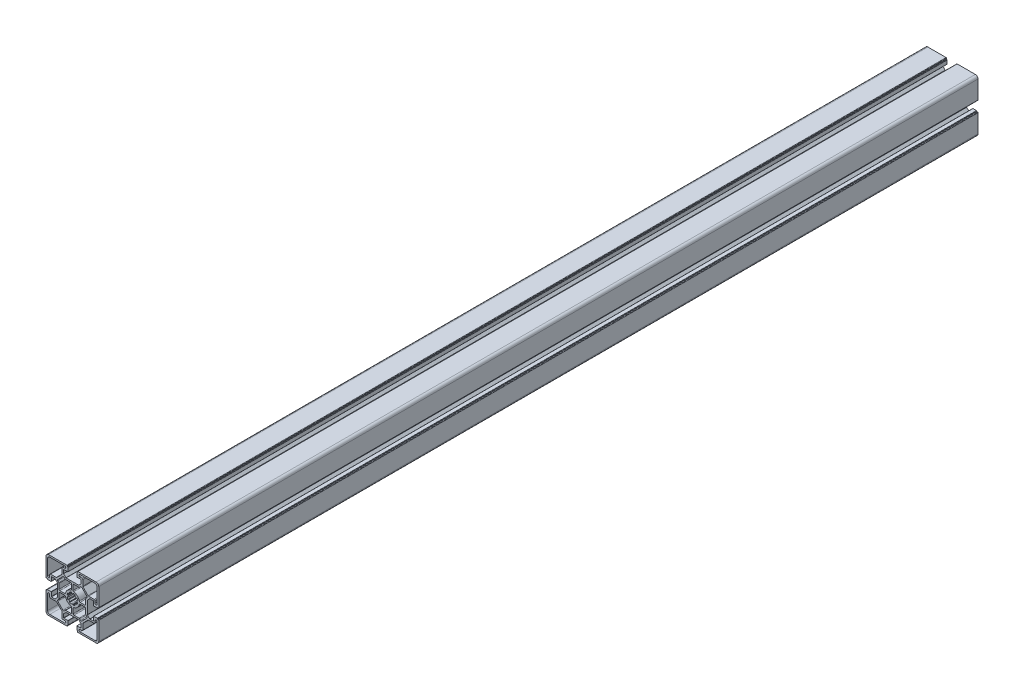
from build123d import *

# Parameters (mm, degrees)
EXTRUDE_1_DEPTH = 1000


with BuildPart() as part:
    # Эскиз1 → Бобышка-Вытянуть1 (new body)
    with BuildSketch(Plane.XY):
        with BuildLine():
            Line((10.939107633, 13.594528117), (8.256260181, 10.911682664))
            ThreePointArc((8.256260181, 10.911682664), (8.1913755, 10.868328133), (8.114838815, 10.853104047))
            Line((8.114838815, 10.853104047), (-6.219481344, 10.853104047))
            ThreePointArc((-6.219481344, 10.853104047), (-6.29601803, 10.868328133), (-6.36090271, 10.911682664))
            Line((-6.36090271, 10.911682664), (-9.043750162, 13.594528117))
            ThreePointArc((-9.043750162, 13.594528117), (-9.087104924, 13.659413063), (-9.102329092, 13.735950089))
            Line((-9.102329092, 13.735950089), (-9.102329092, 17.653103196))
            ThreePointArc((-9.102329092, 17.653103196), (-9.043750199, 17.794525153), (-8.902328242, 17.853104046))
            Line((-8.902328242, 17.853104046), (-4.252328945, 17.853104046))
            ThreePointArc((-4.252328945, 17.853104046), (-4.110906987, 17.911682939), (-4.052328095, 18.053104897))
            Line((-4.052328095, 18.053104897), (-4.052328095, 22.05310527))
            ThreePointArc((-4.052328095, 22.05310527), (-4.140195702, 22.265236439), (-4.35232687, 22.353104046))
            Line((-4.35232687, 22.353104046), (-4.552319317, 22.353104046))
            ThreePointArc((-4.552319317, 22.353104046), (-4.764450486, 22.440971653), (-4.852318093, 22.653102822))
            Line((-4.852318093, 22.653102822), (-4.852318093, 23.353104321))
            ThreePointArc((-4.852318093, 23.353104321), (-4.998764593, 23.706657447), (-5.352317719, 23.853103947))
            Line((-5.352317719, 23.853103947), (-26.052328498, 23.853103947))
            ThreePointArc((-26.052328498, 23.853103947), (-28.173647609, 22.974424801), (-29.052326755, 20.85310569))
            Line((-29.052326755, 20.85310569), (-29.052326755, 0.153095213))
            ThreePointArc((-29.052326755, 0.153095213), (-28.905880255, -0.200457913), (-28.552327128, -0.346904413))
            Line((-28.552327128, -0.346904413), (-27.852326458, -0.346904413))
            ThreePointArc((-27.852326458, -0.346904413), (-27.640194582, -0.434772313), (-27.552326682, -0.646904189))
            Line((-27.552326682, -0.646904189), (-27.552326682, -0.846892625))
            ThreePointArc((-27.552326682, -0.846892625), (-27.464458779, -1.05902451), (-27.252326894, -1.146892413))
            Line((-27.252326894, -1.146892413), (-23.252327233, -1.146892413))
            ThreePointArc((-23.252327233, -1.146892413), (-23.110905629, -1.088313667), (-23.052326882, -0.946892063))
            Line((-23.052326882, -0.946892063), (-23.052326882, 3.703106436))
            ThreePointArc((-23.052326882, 3.703106436), (-22.993748136, 3.84452804), (-22.852326532, 3.903106787))
            Line((-22.852326532, 3.903106787), (-18.935168424, 3.903106787))
            ThreePointArc((-18.935168424, 3.903106787), (-18.858631895, 3.887882725), (-18.793747359, 3.844528263))
            Line((-18.793747359, 3.844528263), (-16.110902259, 1.161683164))
            ThreePointArc((-16.110902259, 1.161683164), (-16.067547166, 1.096797682), (-16.052322882, 1.020260037))
            Line((-16.052322882, 1.020260037), (-16.052322882, -13.313984723))
            ThreePointArc((-16.052322882, -13.313984723), (-16.067547166, -13.390522368), (-16.110902259, -13.45540785))
            Line((-16.110902259, -13.45540785), (-18.793747359, -16.138252949))
            ThreePointArc((-18.793747359, -16.138252949), (-18.858631895, -16.181607411), (-18.935168424, -16.196831473))
            Line((-18.935168424, -16.196831473), (-22.852326532, -16.196831473))
            ThreePointArc((-22.852326532, -16.196831473), (-22.993748136, -16.138252726), (-23.052326882, -15.996831122))
            Line((-23.052326882, -15.996831122), (-23.052326882, -11.346832623))
            ThreePointArc((-23.052326882, -11.346832623), (-23.110905629, -11.205411019), (-23.252327233, -11.146832273))
            Line((-23.252327233, -11.146832273), (-27.252326894, -11.146832273))
            ThreePointArc((-27.252326894, -11.146832273), (-27.464458779, -11.234700176), (-27.552326682, -11.446832061))
            Line((-27.552326682, -11.446832061), (-27.552326682, -11.646820497))
            ThreePointArc((-27.552326682, -11.646820497), (-27.640194582, -11.858952373), (-27.852326458, -11.946820273))
            Line((-27.852326458, -11.946820273), (-28.552327128, -11.946820273))
            ThreePointArc((-28.552327128, -11.946820273), (-28.905880255, -12.093266773), (-29.052326755, -12.446819899))
            Line((-29.052326755, -12.446819899), (-29.052326755, -33.146830376))
            ThreePointArc((-29.052326755, -33.146830376), (-28.173647609, -35.268149487), (-26.052328498, -36.146828633))
            Line((-26.052328498, -36.146828633), (-5.352317719, -36.146828633))
            ThreePointArc((-5.352317719, -36.146828633), (-4.998764593, -36.000382133), (-4.852318093, -35.646829007))
            Line((-4.852318093, -35.646829007), (-4.852318093, -34.946827508))
            ThreePointArc((-4.852318093, -34.946827508), (-4.764450486, -34.734696339), (-4.552319317, -34.646828732))
            Line((-4.552319317, -34.646828732), (-4.35232687, -34.646828732))
            ThreePointArc((-4.35232687, -34.646828732), (-4.140195702, -34.558961125), (-4.052328095, -34.346829956))
            Line((-4.052328095, -34.346829956), (-4.052328095, -30.346829583))
            ThreePointArc((-4.052328095, -30.346829583), (-4.110906987, -30.205407625), (-4.252328945, -30.146828732))
            Line((-4.252328945, -30.146828732), (-8.902328242, -30.146828732))
            ThreePointArc((-8.902328242, -30.146828732), (-9.043750199, -30.088249839), (-9.102329092, -29.946827882))
            Line((-9.102329092, -29.946827882), (-9.102329092, -26.029674775))
            ThreePointArc((-9.102329092, -26.029674775), (-9.087104924, -25.953137749), (-9.043750162, -25.888252803))
            Line((-9.043750162, -25.888252803), (-6.36090271, -23.20540735))
            ThreePointArc((-6.36090271, -23.20540735), (-6.29601803, -23.162052819), (-6.219481344, -23.146828733))
            Line((-6.219481344, -23.146828733), (8.114838815, -23.146828733))
            ThreePointArc((8.114838815, -23.146828733), (8.1913755, -23.162052819), (8.256260181, -23.20540735))
            Line((8.256260181, -23.20540735), (10.939107633, -25.888252803))
            ThreePointArc((10.939107633, -25.888252803), (10.982462395, -25.953137749), (10.997686563, -26.029674775))
            Line((10.997686563, -26.029674775), (10.997686563, -29.946827882))
            ThreePointArc((10.997686563, -29.946827882), (10.93910767, -30.088249839), (10.797685712, -30.146828732))
            Line((10.797685712, -30.146828732), (6.147686416, -30.146828732))
            ThreePointArc((6.147686416, -30.146828732), (6.006264458, -30.205407625), (5.947685565, -30.346829583))
            Line((5.947685565, -30.346829583), (5.947685565, -34.346829956))
            ThreePointArc((5.947685565, -34.346829956), (6.035553173, -34.558961125), (6.247684341, -34.646828732))
            Line((6.247684341, -34.646828732), (6.447676788, -34.646828732))
            ThreePointArc((6.447676788, -34.646828732), (6.659807956, -34.734696339), (6.747675564, -34.946827508))
            Line((6.747675564, -34.946827508), (6.747675564, -35.646829007))
            ThreePointArc((6.747675564, -35.646829007), (6.894122064, -36.000382133), (7.24767519, -36.146828633))
            Line((7.24767519, -36.146828633), (27.947685969, -36.146828633))
            ThreePointArc((27.947685969, -36.146828633), (30.06900508, -35.268149487), (30.947684225, -33.146830376))
            Line((30.947684225, -33.146830376), (30.947684225, -12.446819899))
            ThreePointArc((30.947684225, -12.446819899), (30.801237725, -12.093266773), (30.447684599, -11.946820273))
            Line((30.447684599, -11.946820273), (29.747683929, -11.946820273))
            ThreePointArc((29.747683929, -11.946820273), (29.535552053, -11.858952373), (29.447684153, -11.646820497))
            Line((29.447684153, -11.646820497), (29.447684153, -11.446832061))
            ThreePointArc((29.447684153, -11.446832061), (29.359816249, -11.234700176), (29.147684365, -11.146832273))
            Line((29.147684365, -11.146832273), (25.147684704, -11.146832273))
            ThreePointArc((25.147684704, -11.146832273), (25.006263099, -11.205411019), (24.947684353, -11.346832623))
            Line((24.947684353, -11.346832623), (24.947684353, -15.996831122))
            ThreePointArc((24.947684353, -15.996831122), (24.889105607, -16.138252726), (24.747684002, -16.196831473))
            Line((24.747684002, -16.196831473), (20.830525895, -16.196831473))
            ThreePointArc((20.830525895, -16.196831473), (20.753989366, -16.181607411), (20.689104829, -16.138252949))
            Line((20.689104829, -16.138252949), (18.00625973, -13.45540785))
            ThreePointArc((18.00625973, -13.45540785), (17.962904637, -13.390522368), (17.947680353, -13.313984723))
            Line((17.947680353, -13.313984723), (17.947680353, 1.020260037))
            ThreePointArc((17.947680353, 1.020260037), (17.962904637, 1.096797682), (18.00625973, 1.161683164))
            Line((18.00625973, 1.161683164), (20.689104829, 3.844528263))
            ThreePointArc((20.689104829, 3.844528263), (20.753989366, 3.887882725), (20.830525895, 3.903106787))
            Line((20.830525895, 3.903106787), (24.747684002, 3.903106787))
            ThreePointArc((24.747684002, 3.903106787), (24.889105607, 3.84452804), (24.947684353, 3.703106436))
            Line((24.947684353, 3.703106436), (24.947684353, -0.946892063))
            ThreePointArc((24.947684353, -0.946892063), (25.006263099, -1.088313667), (25.147684704, -1.146892413))
            Line((25.147684704, -1.146892413), (29.147684365, -1.146892413))
            ThreePointArc((29.147684365, -1.146892413), (29.359816249, -1.05902451), (29.447684153, -0.846892625))
            Line((29.447684153, -0.846892625), (29.447684153, -0.646904189))
            ThreePointArc((29.447684153, -0.646904189), (29.535552053, -0.434772313), (29.747683929, -0.346904413))
            Line((29.747683929, -0.346904413), (30.447684599, -0.346904413))
            ThreePointArc((30.447684599, -0.346904413), (30.801237725, -0.200457913), (30.947684225, 0.153095213))
            Line((30.947684225, 0.153095213), (30.947684225, 20.85310569))
            ThreePointArc((30.947684225, 20.85310569), (30.06900508, 22.974424801), (27.947685969, 23.853103947))
            Line((27.947685969, 23.853103947), (7.24767519, 23.853103947))
            ThreePointArc((7.24767519, 23.853103947), (6.894122064, 23.706657447), (6.747675564, 23.353104321))
            Line((6.747675564, 23.353104321), (6.747675564, 22.653102822))
            ThreePointArc((6.747675564, 22.653102822), (6.659807956, 22.440971653), (6.447676788, 22.353104046))
            Line((6.447676788, 22.353104046), (6.247684341, 22.353104046))
            ThreePointArc((6.247684341, 22.353104046), (6.035553173, 22.265236439), (5.947685565, 22.05310527))
            Line((5.947685565, 22.05310527), (5.947685565, 18.053104897))
            ThreePointArc((5.947685565, 18.053104897), (6.006264458, 17.911682939), (6.147686416, 17.853104046))
            Line((6.147686416, 17.853104046), (10.797685712, 17.853104046))
            ThreePointArc((10.797685712, 17.853104046), (10.93910767, 17.794525153), (10.997686563, 17.653103196))
            Line((10.997686563, 17.653103196), (10.997686563, 13.735950089))
            ThreePointArc((10.997686563, 13.735950089), (10.982462395, 13.659413063), (10.939107633, 13.594528117))
        make_face()
        with BuildLine():
            Line((16.147671397, -4.246868232), (16.147670397, 1.434505253))
            ThreePointArc((16.147670397, 1.434505253), (16.223790801, 1.817188396), (16.440563489, 2.141611431))
            Line((16.440563489, 2.141611431), (17.49497809, 3.196025032))
            ThreePointArc((17.49497809, 3.196025032), (17.787871723, 3.903132188), (17.494978303, 4.610239433))
            Line((17.494978303, 4.610239433), (11.704776746, 10.400438989))
            ThreePointArc((11.704776746, 10.400438989), (10.997669862, 10.693331751), (10.290563584, 10.400437526))
            Line((10.290563584, 10.400437526), (9.236153349, 9.346023291))
            ThreePointArc((9.236153349, 9.346023291), (8.911730209, 9.129250011), (8.529046695, 9.053129339))
            Line((8.529046695, 9.053129339), (2.847672955, 9.053129339))
            ThreePointArc((2.847672955, 9.053129339), (2.140566702, 8.760236339), (1.847673702, 8.053130086))
            Line((1.847673702, 8.053130086), (1.847673702, 2.650288806))
            ThreePointArc((1.847673702, 2.650288806), (2.069499422, 2.022240209), (2.636563338, 1.67282612))
            ThreePointArc((2.636563338, 1.67282612), (6.604526839, -0.490014423), (8.767367253, -4.457977993))
            ThreePointArc((8.767367253, -4.457977993), (9.116781336, -5.025041931), (9.744829946, -5.246867661))
            Line((9.744829946, -5.246867661), (15.147672144, -5.246867661))
            ThreePointArc((15.147672144, -5.246867661), (15.854778459, -4.953974599), (16.147671397, -4.246868232))
        make_face(mode=Mode.SUBTRACT)
        with BuildLine():
            Line((25.747669376, 5.703134698), (19.361878962, 5.703134698))
            ThreePointArc((19.361878962, 5.703134698), (18.979194693, 5.779255359), (18.654770674, 5.996028653))
            Line((18.654770674, 5.996028653), (13.090566202, 11.560236125))
            ThreePointArc((13.090566202, 11.560236125), (12.873793186, 11.884660012), (12.797672629, 12.267344032))
            Line((12.797672629, 12.267344032), (12.797672629, 18.653128759))
            ThreePointArc((12.797672629, 18.653128759), (12.50477975, 19.360234851), (11.797673749, 19.653127941))
            Line((11.797673749, 19.653127941), (9.647673619, 19.653128614))
            ThreePointArc((9.647673619, 19.653128614), (8.447671448, 20.853131349), (9.647673995, 22.053133698))
            Line((9.647673995, 22.053133698), (26.647670496, 22.053133698))
            ThreePointArc((26.647670496, 22.053133698), (28.415436129, 21.320901198), (29.147668629, 19.553135566))
            Line((29.147668629, 19.553135566), (29.147668629, 2.553133698))
            ThreePointArc((29.147668629, 2.553133698), (27.947668629, 1.353133698), (26.747668629, 2.553133698))
            Line((26.747668629, 2.553133698), (26.747668629, 4.703135445))
            ThreePointArc((26.747668629, 4.703135445), (26.454775629, 5.410241698), (25.747669376, 5.703134698))
        make_face(mode=Mode.SUBTRACT)
        with BuildLine():
            Line((6.440562886, -5.178305324), (5.871713884, -5.278604324))
            ThreePointArc((5.871713884, -5.278604324), (5.928653499, -5.711074854), (5.947683572, -6.146862343))
            ThreePointArc((5.947683572, -6.146862343), (5.928653499, -6.582649832), (5.871713884, -7.015120362))
            Line((5.871713884, -7.015120362), (6.440562886, -7.115419362))
            ThreePointArc((6.440562886, -7.115419362), (6.775724774, -7.33962351), (6.836427886, -7.738266362))
            ThreePointArc((6.836427886, -7.738266362), (6.583337229, -8.481234645), (6.236941422, -9.185554669))
            ThreePointArc((6.236941422, -9.185554669), (5.912135966, -9.424514919), (5.516604422, -9.346058669))
            Line((5.516604422, -9.346058669), (5.04343151, -9.01473723))
            ThreePointArc((5.04343151, -9.01473723), (4.483211081, -9.6823804), (3.815568316, -10.242601311))
            Line((3.815568316, -10.242601311), (4.146885316, -10.715772311))
            ThreePointArc((4.146885316, -10.715772311), (4.22534853, -11.111322796), (3.986364128, -11.43613523))
            ThreePointArc((3.986364128, -11.43613523), (3.282035765, -11.782535721), (2.539058214, -12.035628787))
            ThreePointArc((2.539058214, -12.035628787), (2.140409591, -11.974921162), (1.916209712, -11.639748738))
            Line((1.916209712, -11.639748738), (1.815927659, -11.07088943))
            ThreePointArc((1.815927659, -11.07088943), (1.383461578, -11.127826804), (0.947678735, -11.146855444))
            ThreePointArc((0.947678735, -11.146855444), (0.511895892, -11.127826804), (0.079429812, -11.07088943))
            Line((0.079429812, -11.07088943), (-0.020852241, -11.639748738))
            ThreePointArc((-0.020852241, -11.639748738), (-0.245052121, -11.974921162), (-0.643700743, -12.035628787))
            ThreePointArc((-0.643700743, -12.035628787), (-1.386678294, -11.782535721), (-2.091006657, -11.43613523))
            ThreePointArc((-2.091006657, -11.43613523), (-2.329991059, -11.111322796), (-2.251527845, -10.715772311))
            Line((-2.251527845, -10.715772311), (-1.920210845, -10.242601311))
            ThreePointArc((-1.920210845, -10.242601311), (-2.58785361, -9.6823804), (-3.148074039, -9.01473723))
            Line((-3.148074039, -9.01473723), (-3.621246951, -9.346058669))
            ThreePointArc((-3.621246951, -9.346058669), (-4.016778495, -9.424514919), (-4.341583951, -9.185554669))
            ThreePointArc((-4.341583951, -9.185554669), (-4.687979758, -8.481234645), (-4.941070415, -7.738266362))
            ThreePointArc((-4.941070415, -7.738266362), (-4.880367303, -7.33962351), (-4.545205415, -7.115419362))
            Line((-4.545205415, -7.115419362), (-3.976356414, -7.015120362))
            ThreePointArc((-3.976356414, -7.015120362), (-4.033296028, -6.582649832), (-4.052326101, -6.146862343))
            ThreePointArc((-4.052326101, -6.146862343), (-4.033296028, -5.711074854), (-3.976356414, -5.278604324))
            Line((-3.976356414, -5.278604324), (-4.545205415, -5.178305324))
            ThreePointArc((-4.545205415, -5.178305324), (-4.880367303, -4.954101176), (-4.941070415, -4.555458324))
            ThreePointArc((-4.941070415, -4.555458324), (-4.687979758, -3.81249004), (-4.341583951, -3.108170017))
            ThreePointArc((-4.341583951, -3.108170017), (-4.016778495, -2.869209767), (-3.621246951, -2.947666017))
            Line((-3.621246951, -2.947666017), (-3.148074039, -3.278987456))
            ThreePointArc((-3.148074039, -3.278987456), (-2.58785361, -2.611344286), (-1.920210845, -2.051123375))
            Line((-1.920210845, -2.051123375), (-2.251527845, -1.577952375))
            ThreePointArc((-2.251527845, -1.577952375), (-2.329991059, -1.18240189), (-2.091006657, -0.857589456))
            ThreePointArc((-2.091006657, -0.857589456), (-1.386678294, -0.511188965), (-0.643700743, -0.258095899))
            ThreePointArc((-0.643700743, -0.258095899), (-0.245052121, -0.318803524), (-0.020852241, -0.653975948))
            Line((-0.020852241, -0.653975948), (0.079429812, -1.222835256))
            ThreePointArc((0.079429812, -1.222835256), (0.511895892, -1.165897882), (0.947678735, -1.146869242))
            ThreePointArc((0.947678735, -1.146869242), (1.383461578, -1.165897882), (1.815927659, -1.222835256))
            Line((1.815927659, -1.222835256), (1.916209712, -0.653975948))
            ThreePointArc((1.916209712, -0.653975948), (2.140409591, -0.318803524), (2.539058214, -0.258095899))
            ThreePointArc((2.539058214, -0.258095899), (3.282035765, -0.511188965), (3.986364128, -0.857589456))
            ThreePointArc((3.986364128, -0.857589456), (4.22534853, -1.18240189), (4.146885316, -1.577952375))
            Line((4.146885316, -1.577952375), (3.815568316, -2.051123375))
            ThreePointArc((3.815568316, -2.051123375), (4.483211081, -2.611344286), (5.04343151, -3.278987456))
            Line((5.04343151, -3.278987456), (5.516604422, -2.947666017))
            ThreePointArc((5.516604422, -2.947666017), (5.912135966, -2.869209767), (6.236941422, -3.108170017))
            ThreePointArc((6.236941422, -3.108170017), (6.583337229, -3.81249004), (6.836427886, -4.555458324))
            ThreePointArc((6.836427886, -4.555458324), (6.775724774, -4.954101176), (6.440562886, -5.178305324))
        make_face(mode=Mode.SUBTRACT)
        with BuildLine():
            Line((-14.252313926, -8.046856454), (-14.252312926, -13.728229939))
            ThreePointArc((-14.252312926, -13.728229939), (-14.328433331, -14.110913082), (-14.545206018, -14.435336117))
            Line((-14.545206018, -14.435336117), (-15.599620619, -15.489749718))
            ThreePointArc((-15.599620619, -15.489749718), (-15.892514252, -16.196856874), (-15.599620832, -16.903964119))
            Line((-15.599620832, -16.903964119), (-9.809419276, -22.694163675))
            ThreePointArc((-9.809419276, -22.694163675), (-9.102312391, -22.987056437), (-8.395206113, -22.694162212))
            Line((-8.395206113, -22.694162212), (-7.340795878, -21.639747977))
            ThreePointArc((-7.340795878, -21.639747977), (-7.016372738, -21.422974697), (-6.633689224, -21.346854025))
            Line((-6.633689224, -21.346854025), (-0.952315484, -21.346854025))
            ThreePointArc((-0.952315484, -21.346854025), (-0.245209231, -21.053961025), (0.047683769, -20.346854772))
            Line((0.047683769, -20.346854772), (0.047683769, -14.944013492))
            ThreePointArc((0.047683769, -14.944013492), (-0.174141952, -14.315964895), (-0.741205867, -13.966550805))
            ThreePointArc((-0.741205867, -13.966550805), (-4.709169368, -11.803710263), (-6.872009782, -7.835746693))
            ThreePointArc((-6.872009782, -7.835746693), (-7.221423865, -7.268682755), (-7.849472475, -7.046857025))
            Line((-7.849472475, -7.046857025), (-13.252314673, -7.046857025))
            ThreePointArc((-13.252314673, -7.046857025), (-13.959420988, -7.339750087), (-14.252313926, -8.046856454))
        make_face(mode=Mode.SUBTRACT)
        with BuildLine():
            Line((-23.852311905, -17.996859384), (-17.466521491, -17.996859384))
            ThreePointArc((-17.466521491, -17.996859384), (-17.083837222, -18.072980045), (-16.759413203, -18.289753339))
            Line((-16.759413203, -18.289753339), (-11.195208731, -23.853960811))
            ThreePointArc((-11.195208731, -23.853960811), (-10.978435715, -24.178384698), (-10.902315158, -24.561068718))
            Line((-10.902315158, -24.561068718), (-10.902315158, -30.946853445))
            ThreePointArc((-10.902315158, -30.946853445), (-10.609422279, -31.653959537), (-9.902316279, -31.946852627))
            Line((-9.902316279, -31.946852627), (-7.752316148, -31.9468533))
            ThreePointArc((-7.752316148, -31.9468533), (-6.552313977, -33.146856035), (-7.752316524, -34.346858384))
            Line((-7.752316524, -34.346858384), (-24.752313026, -34.346858384))
            ThreePointArc((-24.752313026, -34.346858384), (-26.520078658, -33.614625884), (-27.252311158, -31.846860252))
            Line((-27.252311158, -31.846860252), (-27.252311158, -14.846858384))
            ThreePointArc((-27.252311158, -14.846858384), (-26.052311158, -13.646858384), (-24.852311158, -14.846858384))
            Line((-24.852311158, -14.846858384), (-24.852311158, -16.996860131))
            ThreePointArc((-24.852311158, -16.996860131), (-24.559418158, -17.703966384), (-23.852311905, -17.996859384))
        make_face(mode=Mode.SUBTRACT)
        with BuildLine():
            Line((-24.852311158, 2.553133698), (-24.852311158, 4.703135445))
            ThreePointArc((-24.852311158, 4.703135445), (-24.559418158, 5.410241698), (-23.852311905, 5.703134698))
            Line((-23.852311905, 5.703134698), (-17.466521491, 5.703134698))
            ThreePointArc((-17.466521491, 5.703134698), (-17.083837222, 5.779255359), (-16.759413203, 5.996028653))
            Line((-16.759413203, 5.996028653), (-11.195208731, 11.560236125))
            ThreePointArc((-11.195208731, 11.560236125), (-10.978435715, 11.884660012), (-10.902315158, 12.267344032))
            Line((-10.902315158, 12.267344032), (-10.902315158, 18.653128759))
            ThreePointArc((-10.902315158, 18.653128759), (-10.609422279, 19.360234851), (-9.902316279, 19.653127941))
            Line((-9.902316279, 19.653127941), (-7.752316148, 19.653128614))
            ThreePointArc((-7.752316148, 19.653128614), (-6.552313977, 20.853131349), (-7.752316524, 22.053133698))
            Line((-7.752316524, 22.053133698), (-24.752313026, 22.053133698))
            ThreePointArc((-24.752313026, 22.053133698), (-26.520078658, 21.320901198), (-27.252311158, 19.553135566))
            Line((-27.252311158, 19.553135566), (-27.252311158, 2.553133698))
            ThreePointArc((-27.252311158, 2.553133698), (-26.052311158, 1.353133698), (-24.852311158, 2.553133698))
        make_face(mode=Mode.SUBTRACT)
        with BuildLine():
            Line((26.747668629, -14.846858384), (26.747668629, -16.996860131))
            ThreePointArc((26.747668629, -16.996860131), (26.454775629, -17.703966384), (25.747669376, -17.996859384))
            Line((25.747669376, -17.996859384), (19.361878962, -17.996859384))
            ThreePointArc((19.361878962, -17.996859384), (18.979194693, -18.072980045), (18.654770674, -18.289753339))
            Line((18.654770674, -18.289753339), (13.090566202, -23.853960811))
            ThreePointArc((13.090566202, -23.853960811), (12.873793186, -24.178384698), (12.797672629, -24.561068718))
            Line((12.797672629, -24.561068718), (12.797672629, -30.946853445))
            ThreePointArc((12.797672629, -30.946853445), (12.50477975, -31.653959537), (11.797673749, -31.946852627))
            Line((11.797673749, -31.946852627), (9.647673619, -31.9468533))
            ThreePointArc((9.647673619, -31.9468533), (8.447671448, -33.146856035), (9.647673995, -34.346858384))
            Line((9.647673995, -34.346858384), (26.647670496, -34.346858384))
            ThreePointArc((26.647670496, -34.346858384), (28.415436129, -33.614625884), (29.147668629, -31.846860252))
            Line((29.147668629, -31.846860252), (29.147668629, -14.846858384))
            ThreePointArc((29.147668629, -14.846858384), (27.947668629, -13.646858384), (26.747668629, -14.846858384))
        make_face(mode=Mode.SUBTRACT)
        with BuildLine():
            Line((-13.252314673, -5.246867661), (-7.849472475, -5.246867661))
            ThreePointArc((-7.849472475, -5.246867661), (-7.221423865, -5.025041931), (-6.872009782, -4.457977993))
            ThreePointArc((-6.872009782, -4.457977993), (-4.709169368, -0.490014423), (-0.741205867, 1.67282612))
            ThreePointArc((-0.741205867, 1.67282612), (-0.174141952, 2.022240209), (0.047683769, 2.650288806))
            Line((0.047683769, 2.650288806), (0.047683769, 8.053130086))
            ThreePointArc((0.047683769, 8.053130086), (-0.245209231, 8.760236339), (-0.952315484, 9.053129339))
            Line((-0.952315484, 9.053129339), (-6.633689224, 9.053129339))
            ThreePointArc((-6.633689224, 9.053129339), (-7.016372738, 9.129250011), (-7.340795878, 9.346023291))
            Line((-7.340795878, 9.346023291), (-8.395206113, 10.400437526))
            ThreePointArc((-8.395206113, 10.400437526), (-9.102312391, 10.693331751), (-9.809419276, 10.400438989))
            Line((-9.809419276, 10.400438989), (-15.599620832, 4.610239433))
            ThreePointArc((-15.599620832, 4.610239433), (-15.892514252, 3.903132188), (-15.599620619, 3.196025032))
            Line((-15.599620619, 3.196025032), (-14.545206018, 2.141611431))
            ThreePointArc((-14.545206018, 2.141611431), (-14.328433331, 1.817188396), (-14.252312926, 1.434505253))
            Line((-14.252312926, 1.434505253), (-14.252313926, -4.246868232))
            ThreePointArc((-14.252313926, -4.246868232), (-13.959420988, -4.953974599), (-13.252314673, -5.246867661))
        make_face(mode=Mode.SUBTRACT)
        with BuildLine():
            Line((15.147672144, -7.046857025), (9.744829946, -7.046857025))
            ThreePointArc((9.744829946, -7.046857025), (9.116781336, -7.268682755), (8.767367253, -7.835746693))
            ThreePointArc((8.767367253, -7.835746693), (6.604526839, -11.803710263), (2.636563338, -13.966550805))
            ThreePointArc((2.636563338, -13.966550805), (2.069499422, -14.315964895), (1.847673702, -14.944013492))
            Line((1.847673702, -14.944013492), (1.847673702, -20.346854772))
            ThreePointArc((1.847673702, -20.346854772), (2.140566702, -21.053961025), (2.847672955, -21.346854025))
            Line((2.847672955, -21.346854025), (8.529046695, -21.346854025))
            ThreePointArc((8.529046695, -21.346854025), (8.911730209, -21.422974697), (9.236153349, -21.639747977))
            Line((9.236153349, -21.639747977), (10.290563584, -22.694162212))
            ThreePointArc((10.290563584, -22.694162212), (10.997669862, -22.987056437), (11.704776746, -22.694163675))
            Line((11.704776746, -22.694163675), (17.494978303, -16.903964119))
            ThreePointArc((17.494978303, -16.903964119), (17.787871723, -16.196856874), (17.49497809, -15.489749718))
            Line((17.49497809, -15.489749718), (16.440563489, -14.435336117))
            ThreePointArc((16.440563489, -14.435336117), (16.223790801, -14.110913082), (16.147670397, -13.728229939))
            Line((16.147670397, -13.728229939), (16.147671397, -8.046856454))
            ThreePointArc((16.147671397, -8.046856454), (15.854778459, -7.339750087), (15.147672144, -7.046857025))
        make_face(mode=Mode.SUBTRACT)
    extrude(amount=EXTRUDE_1_DEPTH)


solid = part.part
